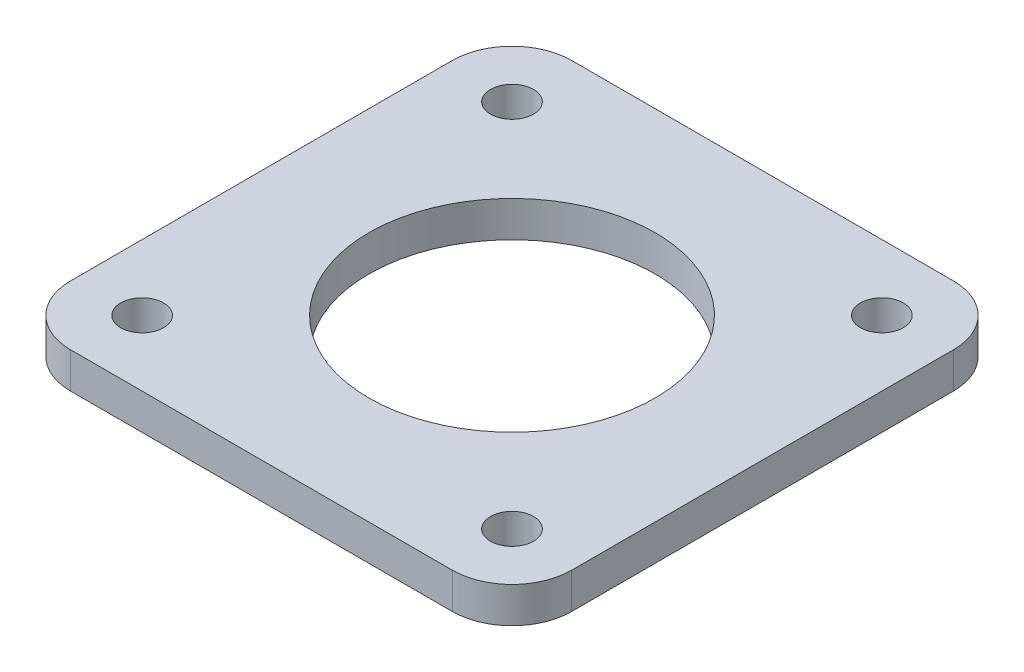
from build123d import *

# Parameters (mm, degrees)
SKETCH1_W            = 42
SKETCH1_H            = 42
BOSS_EXTRUDE1_DEPTH  = 3
M3_CLEARANCE_HOLE1_D = 3.6
SKETCH4_R            = 12
CUT_EXTRUDE1_DEPTH   = 4
FILLET1_R            = 5


with BuildPart() as part:
    # Sketch1 → Boss-Extrude1 (new body)
    with BuildSketch(Plane(origin=(0, 0, 0), x_dir=(1, 0, 0), z_dir=(0, 1, 0))):
        Rectangle(SKETCH1_W, SKETCH1_H)
    extrude(amount=BOSS_EXTRUDE1_DEPTH)

    # M3 Clearance Hole1 (through all)
    with Locations(Plane(origin=(0, 3, 0), x_dir=(1, 0, 0), z_dir=(0, 1, 0))):
        with Locations((-15.5, 15.5), (-15.5, -15.5), (15.5, -15.5), (15.5, 15.5)):
            Hole(M3_CLEARANCE_HOLE1_D / 2)

    # Sketch4 → Cut-Extrude1 (cut, through all)
    with BuildSketch(Plane(origin=(0, 3, 0), x_dir=(1, 0, 0), z_dir=(0, 1, 0))):
        Circle(SKETCH4_R)
    extrude(amount=-CUT_EXTRUDE1_DEPTH, mode=Mode.SUBTRACT)

    # Fillet1
    fillet1_edges = [part.edges().sort_by_distance(p)[0] for p in [
        (-21, 1.5, -21),
        (21, 1.5, -21),
        (21, 1.5, 21),
        (-21, 1.5, 21),
    ]]
    fillet(fillet1_edges, radius=FILLET1_R)


solid = part.part
